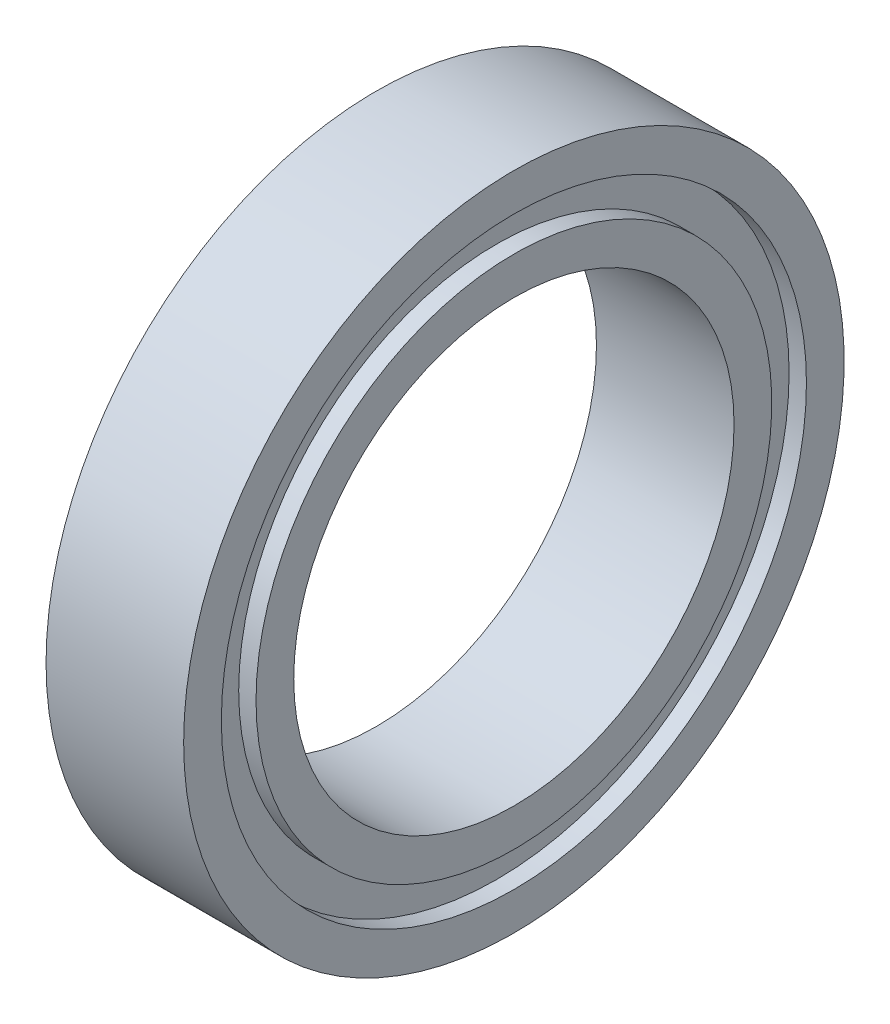
from build123d import *


with BuildPart() as part:
    # Sketch1 → Revolve1 (revolve)
    with BuildSketch(Plane.XY):
        Polygon((-1.984375, 7.4375), (-1.984375, 6.35), (1.984375, 6.35), (1.984375, 7.4375), (1.484375, 7.4375), (1.484375, 8.4375), (1.984375, 8.4375), (1.984375, 9.525), (-1.984375, 9.525), (-1.984375, 8.4375), (-1.484375, 8.4375), (-1.484375, 7.4375), align=None)
    revolve(axis=Axis((-6.83914474, 0, 0), (1, 0, 0)))


solid = part.part
